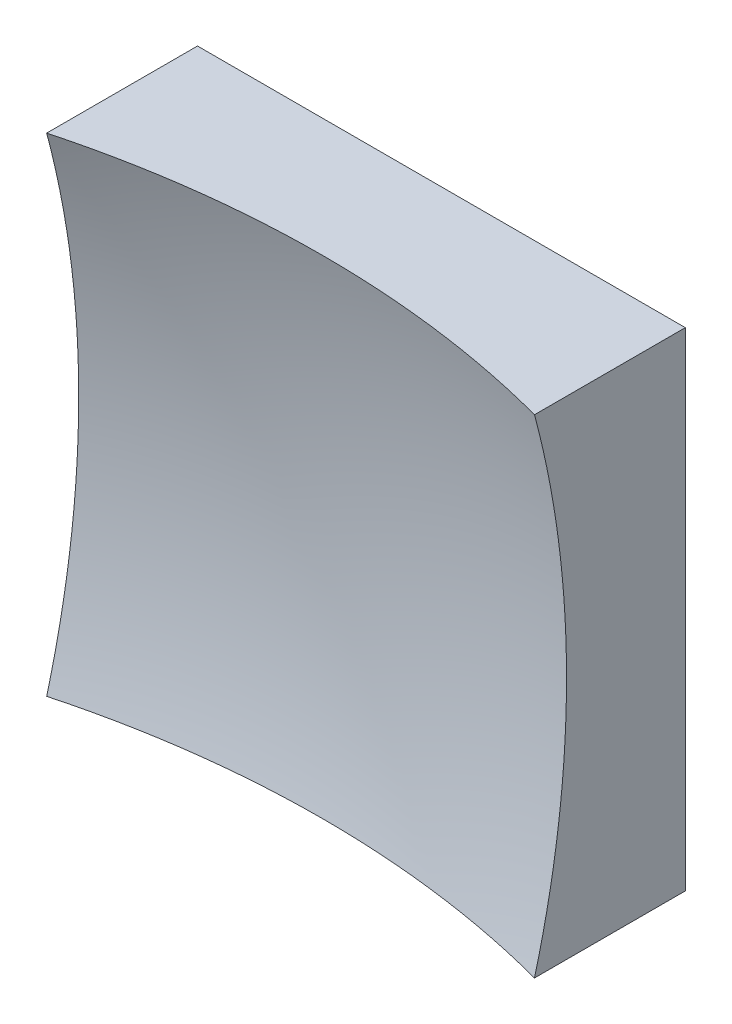
from build123d import *

# Parameters (mm, degrees)
SKETCH_1_W      = 50
SKETCH_1_H      = 50
EXTRUDE_1_DEPTH = 50


with BuildPart() as part:
    # 草图1 → 凸台-拉伸1 (new body)
    with BuildSketch(Plane.XY):
        Rectangle(SKETCH_1_W, SKETCH_1_H)
    extrude(amount=EXTRUDE_1_DEPTH)

    # 草图2 → 切除-旋转2 (revolve, cut)
    with BuildSketch(Plane(origin=(0, 0, 0), x_dir=(1, 0, 0), z_dir=(0, 1, 0))):
        with BuildLine():
            Line((97.484546181, -86.711813537), (0, -86.711813537))
            Line((0, -86.711813537), (0, -9))
            ThreePointArc((0, -9), (62.334506309, -30.805311413), (97.484546181, -86.711813537))
        make_face()
    revolve(axis=Axis((0, 0, 86.711813537), (0, 0, -1)), mode=Mode.SUBTRACT)


solid = part.part
